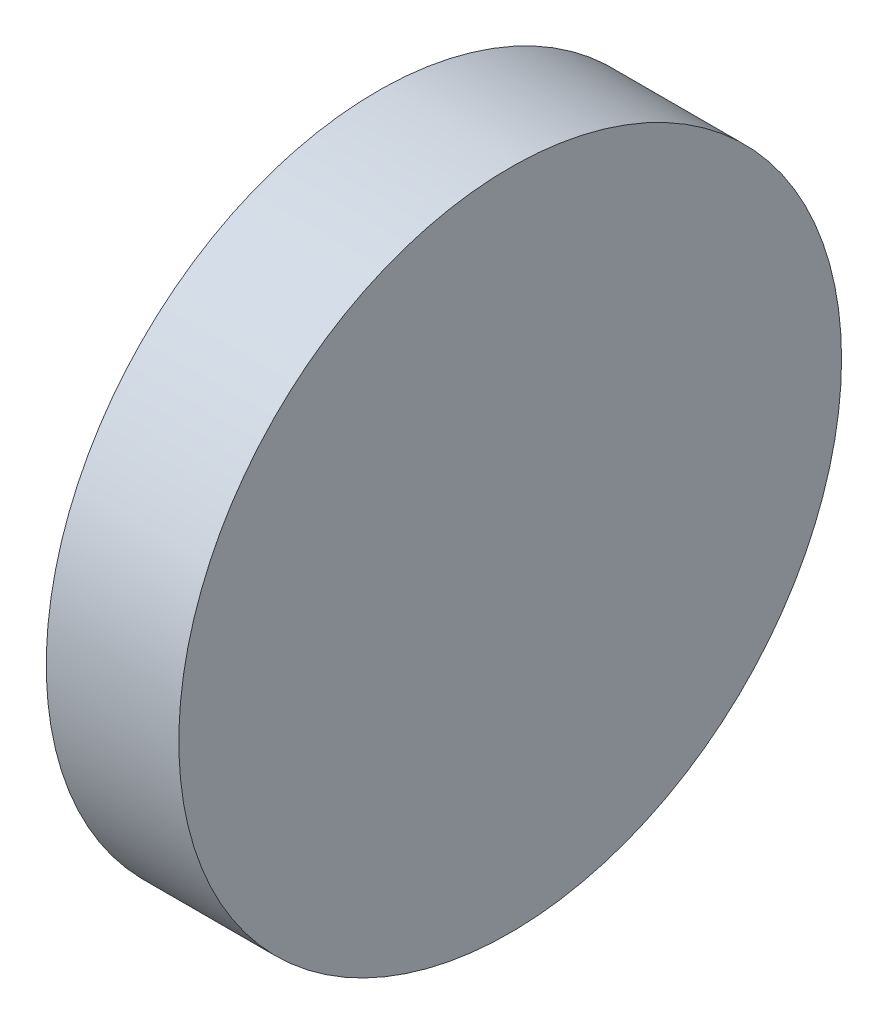
from build123d import *

# Parameters (mm, degrees)
SKETCH_1_W = 10
SKETCH_1_H = 25


with BuildPart() as part:
    # 草图1 → 旋转1 (revolve)
    with BuildSketch(Plane.XY, mode=Mode.PRIVATE) as revolve_1_sk:
        with Locations((525.576029003, 142.392980958)):
            Rectangle(SKETCH_1_W, SKETCH_1_H)
    revolve(revolve_1_sk.sketch.rotate(Axis((530.576029003, 154.892980958, 0), (-1, 0, 0)), 270), axis=Axis((530.576029003, 154.892980958, 0), (-1, 0, 0)))  # turned: the seam where the file's is


solid = part.part
